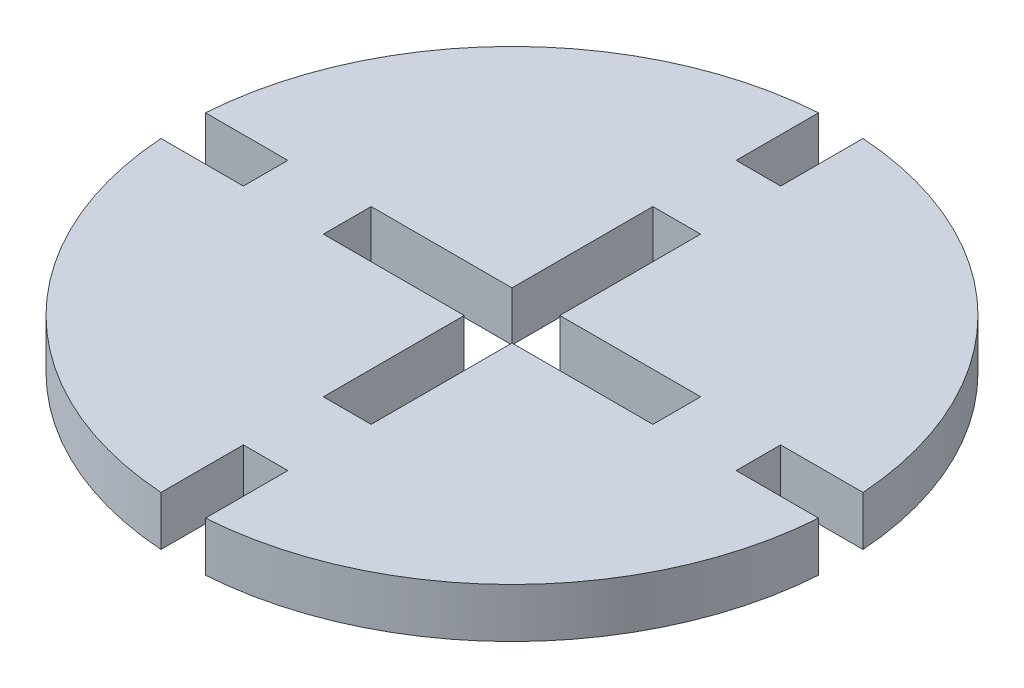
from build123d import *

# Parameters (mm, degrees)
BOSS_EXTRUDE1_DEPTH = 3
CUT_EXTRUDE1_REACH  = 5


with BuildPart() as part:
    # Sketch1 → Boss-Extrude1 (new body)
    with BuildSketch(Plane(origin=(0, 0, 0), x_dir=(1, 0, 0), z_dir=(0, 1, 0))):
        with BuildLine():
            Line((1.35, 14.954385483), (-1.35, 14.954385483))
            Line((-1.35, 14.954385483), (-1.35, 19.954385483))
            ThreePointArc((-1.35, 19.954385483), (-14.142135624, 14.142135624), (-19.954385483, 1.35))
            Line((-19.954385483, 1.35), (-14.954385483, 1.35))
            Line((-14.954385483, 1.35), (-14.954385483, -1.35))
            Line((-14.954385483, -1.35), (-19.954385483, -1.35))
            ThreePointArc((-19.954385483, -1.35), (-14.142135624, -14.142135624), (-1.35, -19.954385483))
            Line((-1.35, -19.954385483), (-1.35, -14.954385483))
            Line((-1.35, -14.954385483), (1.35, -14.954385483))
            Line((1.35, -14.954385483), (1.35, -19.954385483))
            ThreePointArc((1.35, -19.954385483), (14.142135624, -14.142135624), (19.954385483, -1.35))
            Line((19.954385483, -1.35), (14.954385483, -1.35))
            Line((14.954385483, -1.35), (14.954385483, 1.35))
            Line((14.954385483, 1.35), (19.954385483, 1.35))
            ThreePointArc((19.954385483, 1.35), (14.142135624, 14.142135624), (1.35, 19.954385483))
            Line((1.35, 19.954385483), (1.35, 14.954385483))
        make_face()
    extrude(amount=BOSS_EXTRUDE1_DEPTH)

    # Sketch3 → Cut-Extrude1 (cut, up to next)
    with BuildSketch(Plane(origin=(0, 3, 0), x_dir=(1, 0, 0), z_dir=(0, 1, 0)), mode=Mode.PRIVATE) as cut_extrude1_sk1:
        Polygon((1.45, 1.45), (10, 1.45), (10, -1.45), (1.45, -1.45), (1.45, -10), (-1.45, -10), (-1.45, -1.45), (-10, -1.45), (-10, 1.45), (-1.45, 1.45), (-1.45, 10), (1.45, 10), align=None)
    cut_extrude1_tool1 = extrude(cut_extrude1_sk1.sketch, amount=-CUT_EXTRUDE1_REACH, mode=Mode.PRIVATE) & part.part
    add(cut_extrude1_tool1.solids().sort_by_distance((0, 3, 0))[0], mode=Mode.SUBTRACT)


solid = part.part
